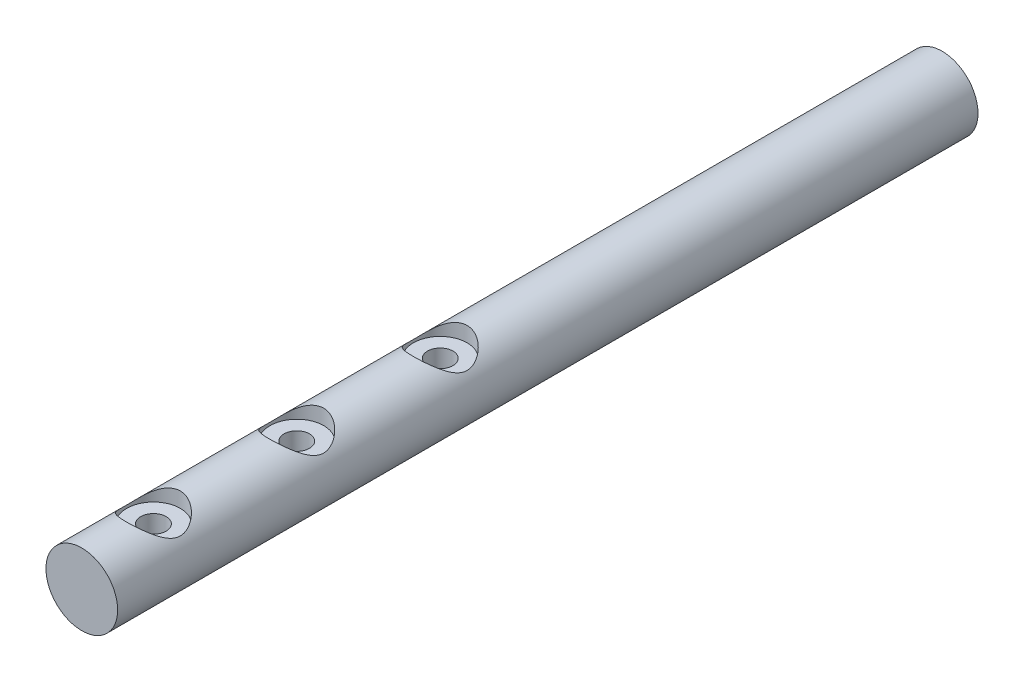
from build123d import *

# Parameters (mm, degrees)
SKETCH1_R                                           = 6.35
BOSS_EXTRUDE1_DEPTH                                 = 152.4
CBORE_FOR_8_BINDING_HEAD_MACHINE_SCREW1_D           = 4.4958
CBORE_FOR_8_BINDING_HEAD_MACHINE_SCREW1_CBORE_D     = 9.525
CBORE_FOR_8_BINDING_HEAD_MACHINE_SCREW1_CBORE_DEPTH = 2.667
CBORE_FOR_8_BINDING_HEAD_MACHINE_SC_2_D             = 4.4958
CBORE_FOR_8_BINDING_HEAD_MACHINE_SC_2_CBORE_D       = 9.525
CBORE_FOR_8_BINDING_HEAD_MACHINE_SC_2_CBORE_DEPTH   = 2.667
CBORE_FOR_8_BINDING_HEAD_MACHINE_SC_3_D             = 4.4958
CBORE_FOR_8_BINDING_HEAD_MACHINE_SC_3_CBORE_D       = 9.525
CBORE_FOR_8_BINDING_HEAD_MACHINE_SC_3_CBORE_DEPTH   = 2.667


with BuildPart() as part:
    # Sketch1 → Boss-Extrude1 (new body)
    with BuildSketch(Plane.XY):
        Circle(SKETCH1_R)
    extrude(amount=BOSS_EXTRUDE1_DEPTH)

    # CBORE for #8 Binding Head Machine Screw1 (through all)
    with Locations(Plane(origin=(-0.016915507, 6.34997747, 139.69710088), x_dir=(0.999996452, 0.002663859, 0), z_dir=(-0.002663859, 0.999996452, 0))):
        with Locations((0, 0)):
            CounterBoreHole(CBORE_FOR_8_BINDING_HEAD_MACHINE_SCREW1_D / 2, CBORE_FOR_8_BINDING_HEAD_MACHINE_SCREW1_CBORE_D / 2, CBORE_FOR_8_BINDING_HEAD_MACHINE_SCREW1_CBORE_DEPTH)

    # CBORE for _8 Binding Head Machine Sc 2 (through all)
    with Locations(Plane(origin=(-0.027009151, 6.349942559, 114.302510667), x_dir=(0.999990956, 0.004253, 0), z_dir=(-0.004253, 0.999990956, 0))):
        with Locations((0, 0)):
            CounterBoreHole(CBORE_FOR_8_BINDING_HEAD_MACHINE_SC_2_D / 2, CBORE_FOR_8_BINDING_HEAD_MACHINE_SC_2_CBORE_D / 2, CBORE_FOR_8_BINDING_HEAD_MACHINE_SC_2_CBORE_DEPTH)

    # CBORE for _8 Binding Head Machine Sc 3 (through all)
    with Locations(Plane(origin=(-0.003205304, 6.349999191, 88.90178774), x_dir=(0.999999872, 0.000505, 0), z_dir=(-0.000505, 0.999999872, 0))):
        with Locations((0, 0)):
            CounterBoreHole(CBORE_FOR_8_BINDING_HEAD_MACHINE_SC_3_D / 2, CBORE_FOR_8_BINDING_HEAD_MACHINE_SC_3_CBORE_D / 2, CBORE_FOR_8_BINDING_HEAD_MACHINE_SC_3_CBORE_DEPTH)


solid = part.part
